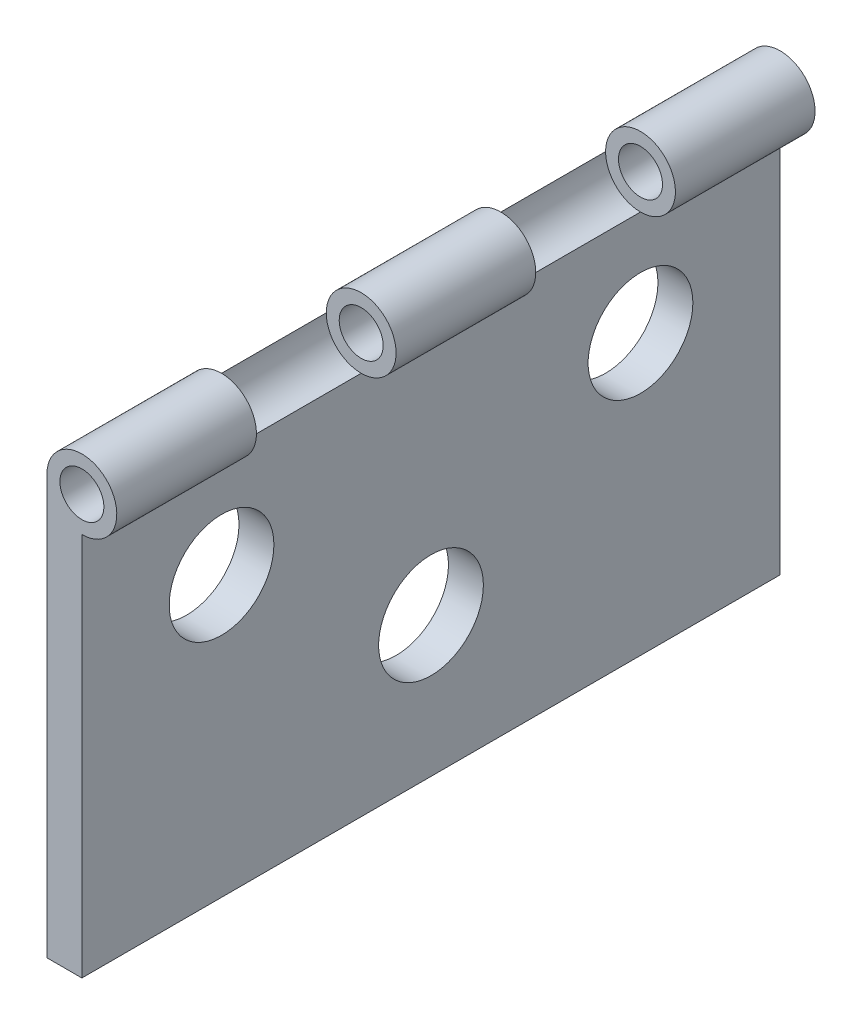
from build123d import *

# Parameters (mm, degrees)
SKETCH1_W           = 50
SKETCH1_H           = 30
SKETCH1_R           = 3.75
BOSS_EXTRUDE1_DEPTH = 2.5
SKETCH3_R           = 2.5
BOSS_EXTRUDE3_DEPTH = 10
SKETCH4_R           = 1.575
CUT_EXTRUDE1_DEPTH  = 50
LPATTERN1_COUNT     = 3
LPATTERN1_PITCH     = 20
CUT_EXTRUDE3_START  = -10
SKETCH5_R           = 2.5
CUT_EXTRUDE3_DEPTH  = 10
CUT_EXTRUDE4_START  = -40
SKETCH5_2_R         = 2.5
CUT_EXTRUDE4_DEPTH  = 10
ESCALA1_SCALE       = 0.5


with BuildPart() as part:
    # Sketch1 → Boss-Extrude1 (new body)
    with BuildSketch(Plane(origin=(0, 0, 0), x_dir=(0, 0, -1), z_dir=(1, 0, 0))):
        with Locations((25, 15)):
            Rectangle(SKETCH1_W, SKETCH1_H)
        with Locations((40, 20)):
            Circle(SKETCH1_R, mode=Mode.SUBTRACT)
        with Locations((25, 10)):
            Circle(SKETCH1_R, mode=Mode.SUBTRACT)
        with Locations((10, 20)):
            Circle(SKETCH1_R, mode=Mode.SUBTRACT)
    extrude(amount=BOSS_EXTRUDE1_DEPTH)

    # Sketch3 → Boss-Extrude3 (add)
    with BuildSketch(Plane(origin=(0, 0, -50), x_dir=(-1, 0, 0), z_dir=(0, 0, -1))):
        with Locations((-2.5, 30)):
            Circle(SKETCH3_R)
    boss_extrude3 = extrude(amount=-BOSS_EXTRUDE3_DEPTH)

    # Sketch4 → Cut-Extrude1 (cut)
    with BuildSketch(Plane(origin=(0, 0, -50), x_dir=(-1, 0, 0), z_dir=(0, 0, -1))):
        with Locations((-2.5, 30)):
            Circle(SKETCH4_R)
    cut_extrude1 = extrude(amount=-CUT_EXTRUDE1_DEPTH, mode=Mode.SUBTRACT)

    # LPattern1: Boss-Extrude3, Cut-Extrude1 ×3
    with Locations(*[(0, 0, i * LPATTERN1_PITCH) for i in range(1, LPATTERN1_COUNT)]):
        add(boss_extrude3)
        add(cut_extrude1, mode=Mode.SUBTRACT)

    # Sketch5 → Cut-Extrude3 (cut)
    with BuildSketch(Plane(origin=(0, 0, -50), x_dir=(-1, 0, 0), z_dir=(0, 0, -1)).offset(CUT_EXTRUDE3_START)):
        with Locations((-2.5, 30)):
            Circle(SKETCH5_R)
    extrude(amount=-CUT_EXTRUDE3_DEPTH, mode=Mode.SUBTRACT)

    # Sketch5_2 → Cut-Extrude4 (cut)
    with BuildSketch(Plane(origin=(0, 0, -50), x_dir=(-1, 0, 0), z_dir=(0, 0, -1)).offset(CUT_EXTRUDE4_START)):
        with Locations((-2.5, 30)):
            Circle(SKETCH5_2_R)
    extrude(amount=CUT_EXTRUDE4_DEPTH, mode=Mode.SUBTRACT)


with BuildPart() as part_1:
    # Escala1: scaled about (0, 0, 0)
    add(part.part.scale(ESCALA1_SCALE))


solid = part_1.part
